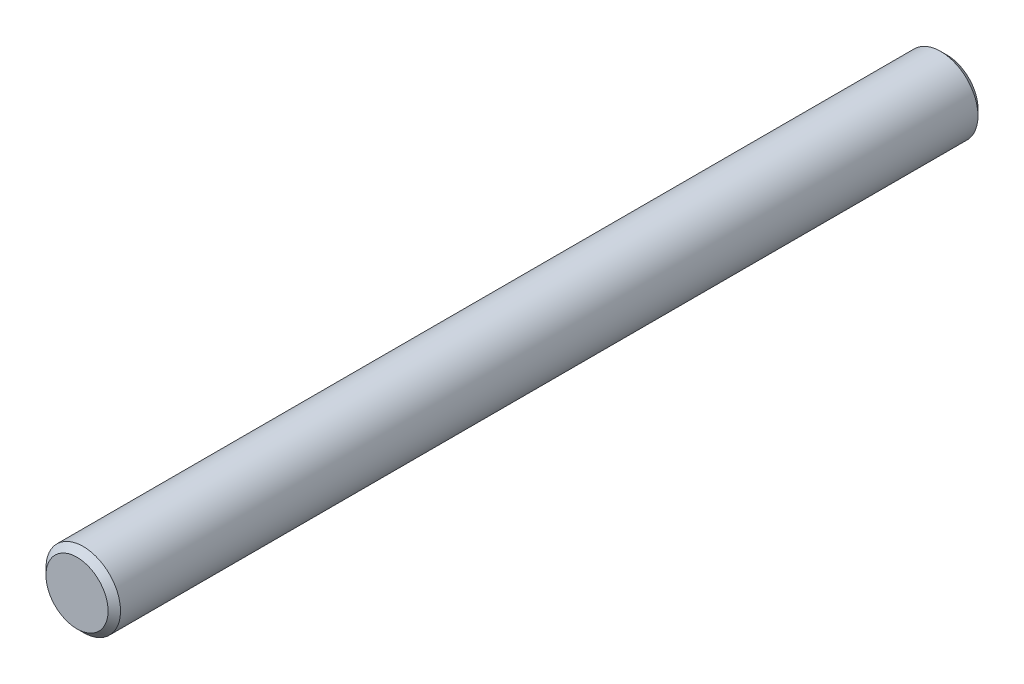
from build123d import *

# Parameters (mm, degrees)
ESQUISSE1_R        = 3
BOSS_EXTRU_1_DEPTH = 70
CHANFREIN1_SIZE    = 0.5


with BuildPart() as part:
    # Esquisse1 → Boss.-Extru.1 (new body)
    with BuildSketch(Plane.XY):
        Circle(ESQUISSE1_R)
    extrude(amount=BOSS_EXTRU_1_DEPTH)

    # Chanfrein1
    chanfrein1_edges = [part.edges().sort_by_distance(p)[0] for p in [
        (-3, 0, 0),
        (-3, 0, 70),
    ]]
    chamfer(chanfrein1_edges, length=CHANFREIN1_SIZE)


solid = part.part
